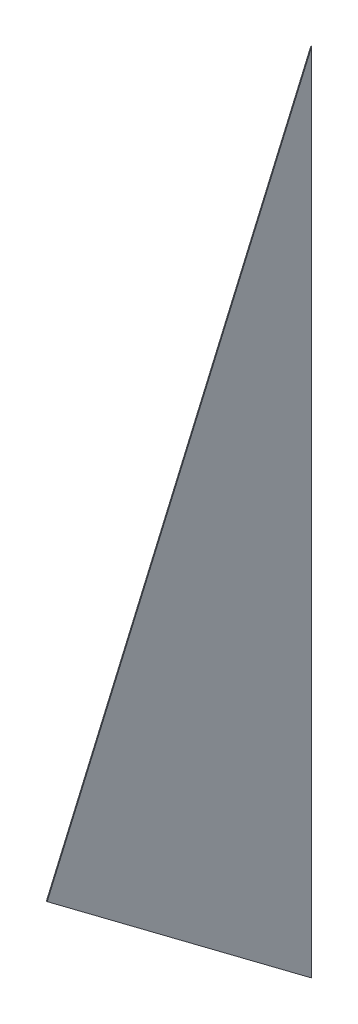
from build123d import *

# Parameters (mm, degrees)
BOSS_EXTRUDE1_DEPTH = 1.5875


with BuildPart() as part:
    # Sketch2 → Boss-Extrude1 (new body, symmetric)
    with BuildSketch(Plane(origin=(0, 0, 0), x_dir=(0, 0, -1), z_dir=(1, 0, 0))):
        Polygon((0, 0), (1016, 2336.8), (1016, -762), align=None)
    extrude(amount=BOSS_EXTRUDE1_DEPTH, both=True)


solid = part.part
